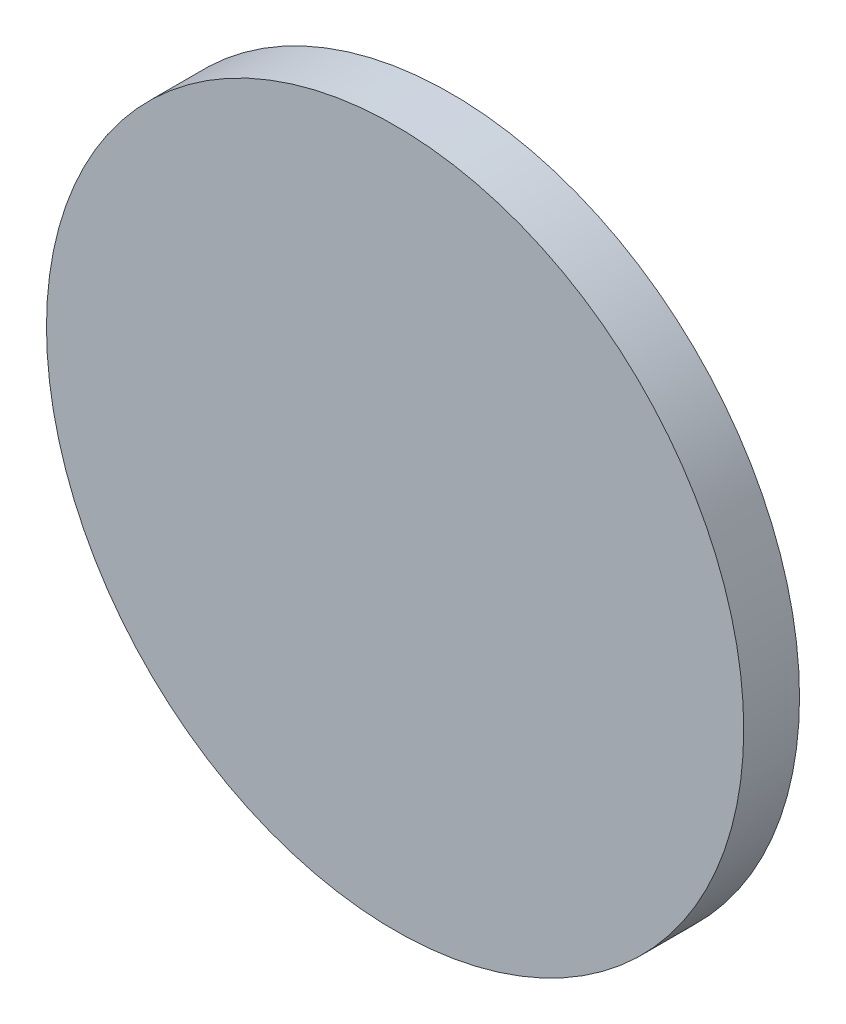
from build123d import *

# Parameters (mm, degrees)
SKETCH_1_R      = 6.25
EXTRUDE_1_DEPTH = 1


with BuildPart() as part:
    # 草图1 → 凸台-拉伸1 (new body)
    with BuildSketch(Plane.XY):
        Circle(SKETCH_1_R)
    extrude(amount=EXTRUDE_1_DEPTH)


solid = part.part
